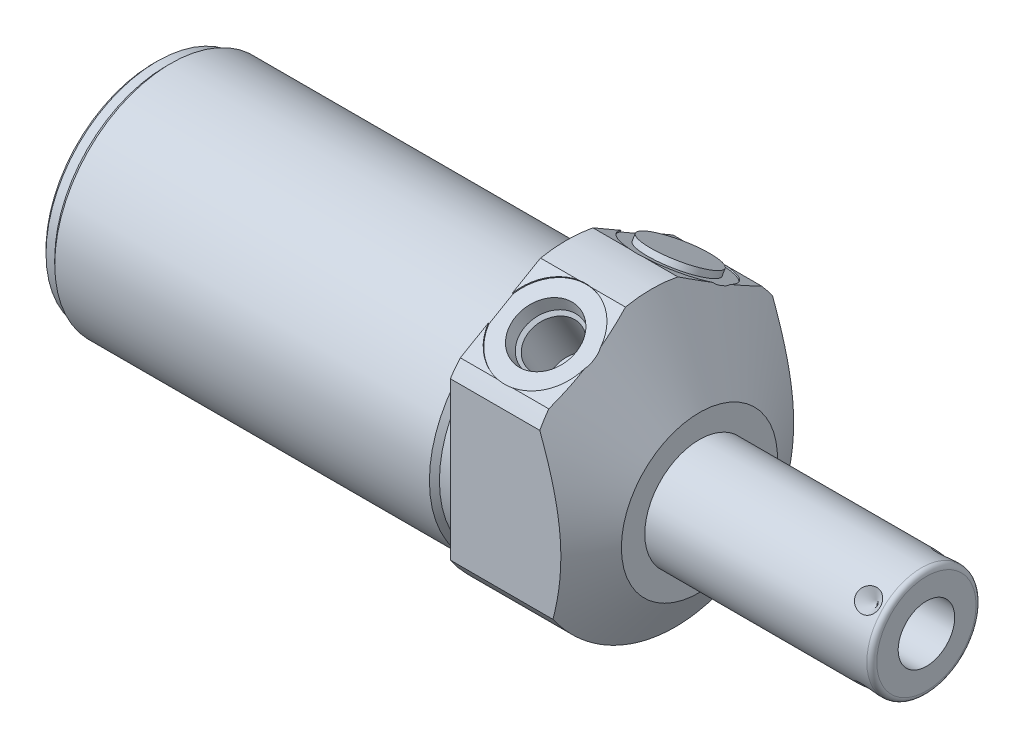
from build123d import *

# Parameters (mm, degrees)
SKETCH1_R           = 28.575
EXTRUDE1_DEPTH      = 27.0002
EXTRUDE1_DEPTH_BACK = 84.1248
CUT_EXTRUDE1_REACH  = 86.125
SKETCH2_R           = 28.575
SKETCH2_R_2         = 23.622
CUT_EXTRUDE3_START  = -27.0002
CUT_EXTRUDE3_DEPTH  = 27.0002
SKETCH18_R          = 9.525
CUT_EXTRUDE4_DEPTH  = 0.254
SKETCH19_R          = 9.525
CUT_EXTRUDE5_DEPTH  = 0.254
CHAMFER1_SIZE       = 0.762
SKETCH15_R          = 6.9469
EXTRUDE2_DEPTH      = 1.27
CIRPATTERN1_COUNT   = 4


with BuildPart() as part:
    # Sketch1 → Extrude1 (new body, two sides)
    with BuildSketch(Plane(origin=(0, 0, 0), x_dir=(0, 0, -1), z_dir=(1, 0, 0))) as extrude1_sk:
        Circle(SKETCH1_R)
    extrude(amount=EXTRUDE1_DEPTH)
    extrude(extrude1_sk.sketch, amount=-EXTRUDE1_DEPTH_BACK)

    # Sketch2 → Cut-Extrude1 (cut, up to next)
    with BuildSketch(Plane(origin=(0, 0, 0), x_dir=(0, 0, -1), z_dir=(1, 0, 0)), mode=Mode.PRIVATE) as cut_extrude1_sk1:
        Circle(SKETCH2_R)
        with Locations((0, -4.191)):
            Circle(SKETCH2_R_2, mode=Mode.SUBTRACT)
    cut_extrude1_tool1 = extrude(cut_extrude1_sk1.sketch, amount=-CUT_EXTRUDE1_REACH, mode=Mode.PRIVATE) & part.part
    add(cut_extrude1_tool1.solids().sort_by_distance((0, 0, 27.766777))[0], mode=Mode.SUBTRACT)

    # Sketch4 → Cut-Extrude3 (cut)
    with BuildSketch(Plane.ZY.offset(CUT_EXTRUDE3_START)):
        with BuildLine():
            Line((23.6855, -25.666178421), (23.6855, 17.476089577))
            Line((23.6855, 17.476089577), (0, 31.150919378))
            Line((0, 31.150919378), (-23.6855, 17.476089577))
            Line((-23.6855, 17.476089577), (-23.6855, -25.666178421))
            ThreePointArc((-23.6855, -25.666178421), (0, 34.925), (23.6855, -25.666178421))
        make_face()
    extrude(amount=CUT_EXTRUDE3_DEPTH, mode=Mode.SUBTRACT)

    # Sketch6 → Cut-Revolve2 (revolve, cut)
    with BuildSketch(Plane.XY, mode=Mode.PRIVATE) as cut_revolve2_sk:
        Polygon((0.750392661, 57.15), (27.0002, 11.684), (27.0002, 57.15), align=None)
    revolve(cut_revolve2_sk.sketch.rotate(Axis((-0.562097706, -4.191, 0), (1, 0, 0)), 270), axis=Axis((-0.562097706, -4.191, 0), (1, 0, 0)), mode=Mode.SUBTRACT)  # turned: the seam where the file's is

    # S2D0002 → Cut-Revolve3 (revolve, cut)
    with BuildSketch(Plane(origin=(9.0932, 23.136869081, 13.372742289), x_dir=(0, 0.5, -0.866025404), z_dir=(1, 0, 0))):
        Polygon((0, 0), (6.1849, 0), (5.642306865, -2.5527), (4.9784, -3.216606865), (4.9784, -13.462), (0, -13.462), align=None)
    revolve(axis=Axis((9.0932, 10.895513396, 6.305192289), (0, 0.866025404, 0.5)), mode=Mode.SUBTRACT)

    # Sketch8 → Cut-Revolve4 (revolve, cut)
    with BuildSketch(Plane(origin=(9.0932, 23.136869081, -13.372742289), x_dir=(0, -0.5, -0.866025404), z_dir=(1, 0, 0))):
        Polygon((0, 0), (6.1849, 0), (5.642306865, -2.5527), (4.9784, -3.216606865), (4.9784, -13.462), (0, -13.462), align=None)
    revolve(axis=Axis((9.0932, 10.895513396, -6.305192289), (0, 0.866025404, -0.5)), mode=Mode.SUBTRACT)

    # Sketch18 → Cut-Extrude4 (cut)
    with BuildSketch(Plane(origin=(0, 23.363189534, 13.488743766), x_dir=(1, 0, 0), z_dir=(0, 0.866025404, 0.5))):
        with Locations((9.0932, -0.0127)):
            Circle(SKETCH18_R)
    extrude(amount=-CUT_EXTRUDE4_DEPTH, mode=Mode.SUBTRACT)

    # Sketch19 → Cut-Extrude5 (cut)
    with BuildSketch(Plane(origin=(0, 23.363189534, -13.488743766), x_dir=(1, 0, 0), z_dir=(0, 0.866025404, -0.5))):
        with Locations((9.0932, 0.0127)):
            Circle(SKETCH19_R)
    extrude(amount=-CUT_EXTRUDE5_DEPTH, mode=Mode.SUBTRACT)

    # Sketch10 → Cut-Revolve6 (revolve, cut)
    with BuildSketch(Plane.XY, mode=Mode.PRIVATE) as cut_revolve6_sk:
        Polygon((0, 19.431), (0, 18.415), (-3.302, 18.415), (-4.318, 19.431), align=None)
    revolve(cut_revolve6_sk.sketch.rotate(Axis((-4.5339, -4.191, 0), (1, 0, 0)), 90), axis=Axis((-4.5339, -4.191, 0), (1, 0, 0)), mode=Mode.SUBTRACT)  # turned: the seam where the file's is

    # Sketch12 → Cut-Revolve8 (revolve, cut)
    with BuildSketch(Plane.XY, mode=Mode.PRIVATE) as cut_revolve8_sk:
        Polygon((-84.1248, 19.431), (-84.1248, 18.415), (-81.5848, 18.415), (-80.5688, 19.431), align=None)
    revolve(cut_revolve8_sk.sketch.rotate(Axis((-84.3026, -4.191, 0), (1, 0, 0)), 90), axis=Axis((-84.3026, -4.191, 0), (1, 0, 0)), mode=Mode.SUBTRACT)  # turned: the seam where the file's is

    # Chamfer1
    chamfer1_edges = [part.edges().sort_by_distance(p)[0] for p in [
        (-84.1248, -4.191, -22.606),
    ]]
    chamfer(chamfer1_edges, length=CHAMFER1_SIZE)

    # Sketch13 → Revolve1 (revolve)
    with BuildSketch(Plane(origin=(0, 0, 0), x_dir=(0, -1, 0), z_dir=(0, 0, 1)), mode=Mode.PRIVATE) as revolve1_sk:
        with BuildLine():
            Line((4.191, 27.0002), (4.191, 73.2028))
            Line((4.191, 73.2028), (14.2875, 73.2028))
            ThreePointArc((14.2875, 73.2028), (15.00592049, 72.90522049), (15.3035, 72.1868))
            Line((15.3035, 72.1868), (15.3035, 27.0002))
            Line((15.3035, 27.0002), (4.191, 27.0002))
        make_face()
    revolve(revolve1_sk.sketch.rotate(Axis((25.10663, -4.191, 0), (1, 0, 0)), 270), axis=Axis((25.10663, -4.191, 0), (1, 0, 0)))  # turned: the seam where the file's is

    # S2D0001 → Cut-Revolve9 (revolve, cut)
    with BuildSketch(Plane(origin=(64.8716, -9.9441, 0), x_dir=(0, -1, 0), z_dir=(0, 0, 1)), mode=Mode.PRIVATE) as cut_revolve9_sk:
        Polygon((0, 8.3312), (0, -8.6868), (-5.7531, -12.143611227), (-5.7531, 8.3312), align=None)
    revolve(cut_revolve9_sk.sketch.rotate(Axis((43.373048211, -4.191, 0), (1, 0, 0)), 270), axis=Axis((43.373048211, -4.191, 0), (1, 0, 0)), mode=Mode.SUBTRACT)  # turned: the seam where the file's is

    # Sketch15 → Extrude2 (add)
    with BuildSketch(Plane(origin=(27.0002, 23.143219081, -13.361743766), x_dir=(0, -0.5, -0.866025404), z_dir=(0, -0.866025404, 0.5))):
        with Locations((0.0127, -17.907)):
            Circle(SKETCH15_R)
    extrude(amount=-EXTRUDE2_DEPTH)

    # Sketch16 → Cut-Revolve10 (revolve, cut)
    with BuildSketch(Plane(origin=(60.9092, 3.666724106, -7.857724106), x_dir=(-1, 0, 0), z_dir=(0, -0.707106781, -0.707106781)), mode=Mode.PRIVATE) as cut_revolve10_sk:
        Polygon((-8.3312, 0), (-5.9182, 0), (-8.3312, -2.413), align=None)
    cut_revolve10 = revolve(cut_revolve10_sk.sketch.rotate(Axis((69.2404, 0.494324135, -4.685324135), (0, 0.707106781, -0.707106781)), 90), axis=Axis((69.2404, 0.494324135, -4.685324135), (0, 0.707106781, -0.707106781)), mode=Mode.SUBTRACT)  # turned: the seam where the file's is

    # CirPattern1: Cut-Revolve10 ×4 about axis
    cirpattern1_axis = Axis((25.10663, -4.191, 0), (-1, 0, 0))
    for i in range(1, CIRPATTERN1_COUNT):
        add(cut_revolve10.rotate(cirpattern1_axis, i * 360 / CIRPATTERN1_COUNT), mode=Mode.SUBTRACT)


solid = part.part
